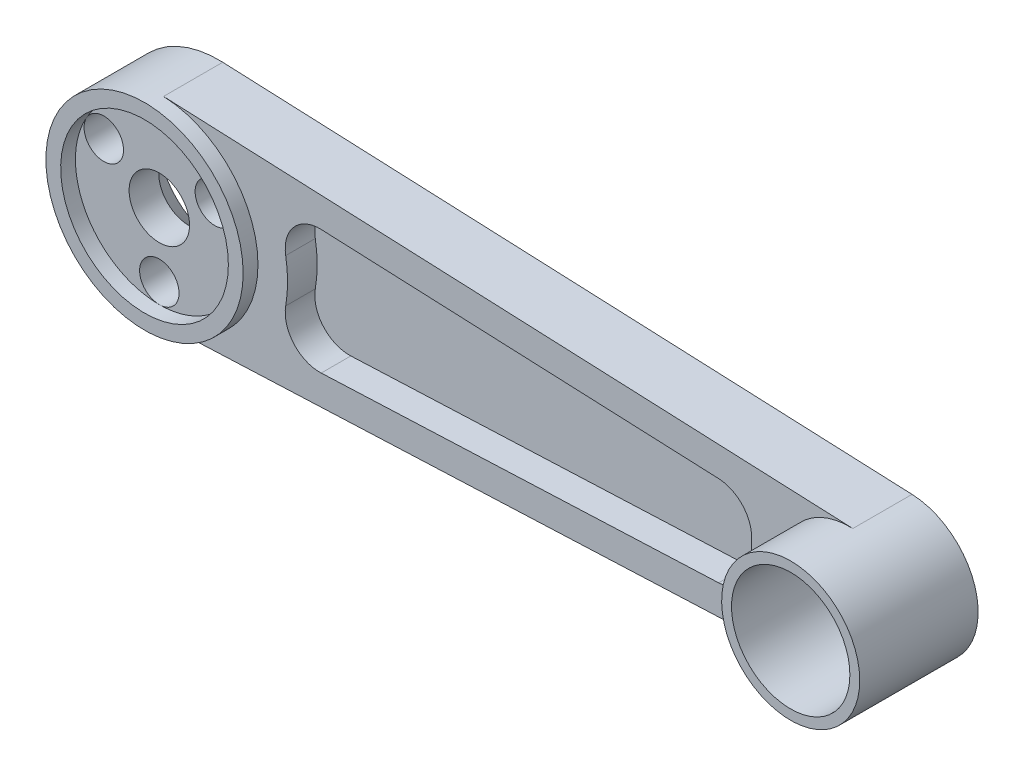
from build123d import *

# Parameters (mm, degrees)
SKETCH1_R           = 7
SKETCH1_R_2         = 6
SKETCH1_R_3         = 3.0625
BOSS_EXTRUDE1_DEPTH = 6
SKETCH2_R           = 2
CUT_EXTRUDE1_DEPTH  = 4.5
SKETCH3_R           = 10
SKETCH3_R_2         = 8.5
BOSS_EXTRUDE2_DEPTH = 1.5
CHAMFER1_SIZE       = 3
SKETCH4_R           = 7
SKETCH4_R_2         = 6
BOSS_EXTRUDE3_DEPTH = 6
CUT_EXTRUDE2_DEPTH  = 3


with BuildPart() as part:
    # Sketch1 → Boss-Extrude1 (new body)
    with BuildSketch(Plane.XY):
        with Locations((70, 0)):
            Circle(SKETCH1_R)
        with Locations((70, 0)):
            Circle(SKETCH1_R_2, mode=Mode.SUBTRACT)
        with BuildLine():
            ThreePointArc((10, 0), (7.221001118, -6.917885722), (0.428571429, -9.990812106))
            Line((0.428571429, -9.990812106), (70.3, -6.993568474))
            ThreePointArc((70.3, -6.993568474), (63, 0), (70.3, 6.993568474))
            Line((70.3, 6.993568474), (0.428571429, 9.990812106))
            ThreePointArc((0.428571429, 9.990812106), (7.221001118, 6.917885722), (10, 0))
        make_face()
        with BuildLine():
            ThreePointArc((0.428571429, 9.990812106), (-10, 0), (0.428571429, -9.990812106))
            ThreePointArc((0.428571429, -9.990812106), (7.221001118, -6.917885722), (10, 0))
            ThreePointArc((10, 0), (7.221001118, 6.917885722), (0.428571429, 9.990812106))
        make_face()
        Circle(SKETCH1_R_3, mode=Mode.SUBTRACT)
    extrude(amount=BOSS_EXTRUDE1_DEPTH)

    # Sketch2 → Cut-Extrude1 (cut)
    with BuildSketch(Plane.XY.offset(6)):
        with Locations((0, -6.5)):
            Circle(SKETCH2_R)
        with Locations((-5.629165125, 3.25)):
            Circle(SKETCH2_R)
        with Locations((5.629165125, 3.25)):
            Circle(SKETCH2_R)
    extrude(amount=-CUT_EXTRUDE1_DEPTH, mode=Mode.SUBTRACT)

    # Sketch3 → Boss-Extrude2 (add)
    with BuildSketch(Plane.XY.offset(6)):
        Circle(SKETCH3_R)
        Circle(SKETCH3_R_2, mode=Mode.SUBTRACT)
    extrude(amount=BOSS_EXTRUDE2_DEPTH)

    # Chamfer1
    chamfer1_edges = [part.edges().sort_by_distance(p)[0] for p in [
        (-3.0625, 0, 0),
    ]]
    chamfer(chamfer1_edges, length=CHAMFER1_SIZE)

    # Sketch4 → Boss-Extrude3 (add)
    with BuildSketch(Plane.XY.offset(6)):
        with Locations((70, 0)):
            Circle(SKETCH4_R)
        with Locations((70, 0)):
            Circle(SKETCH4_R_2, mode=Mode.SUBTRACT)
    extrude(amount=BOSS_EXTRUDE3_DEPTH)

    # Sketch5 → Cut-Extrude2 (cut)
    with BuildSketch(Plane.XY.offset(6)):
        with BuildLine():
            Line((16.409700462, -6.30251781), (56.693086155, -4.574499309))
            ThreePointArc((56.693086155, -4.574499309), (59.165141891, -3.396081679), (60.031915671, -0.798307461))
            ThreePointArc((60.031915671, -0.798307461), (60, 0), (60.031915671, 0.798307461))
            ThreePointArc((60.031915671, 0.798307461), (59.165141891, 3.396081679), (56.693086155, 4.574499309))
            Line((56.693086155, 4.574499309), (16.409700462, 6.30251781))
            ThreePointArc((16.409700462, 6.30251781), (13.631604513, 5.117250755), (12.810673091, 2.210577966))
            ThreePointArc((12.810673091, 2.210577966), (13, 0), (12.810673091, -2.210577966))
            ThreePointArc((12.810673091, -2.210577966), (13.631604513, -5.117250755), (16.409700462, -6.30251781))
        make_face()
    extrude(amount=-CUT_EXTRUDE2_DEPTH, mode=Mode.SUBTRACT)


solid = part.part
